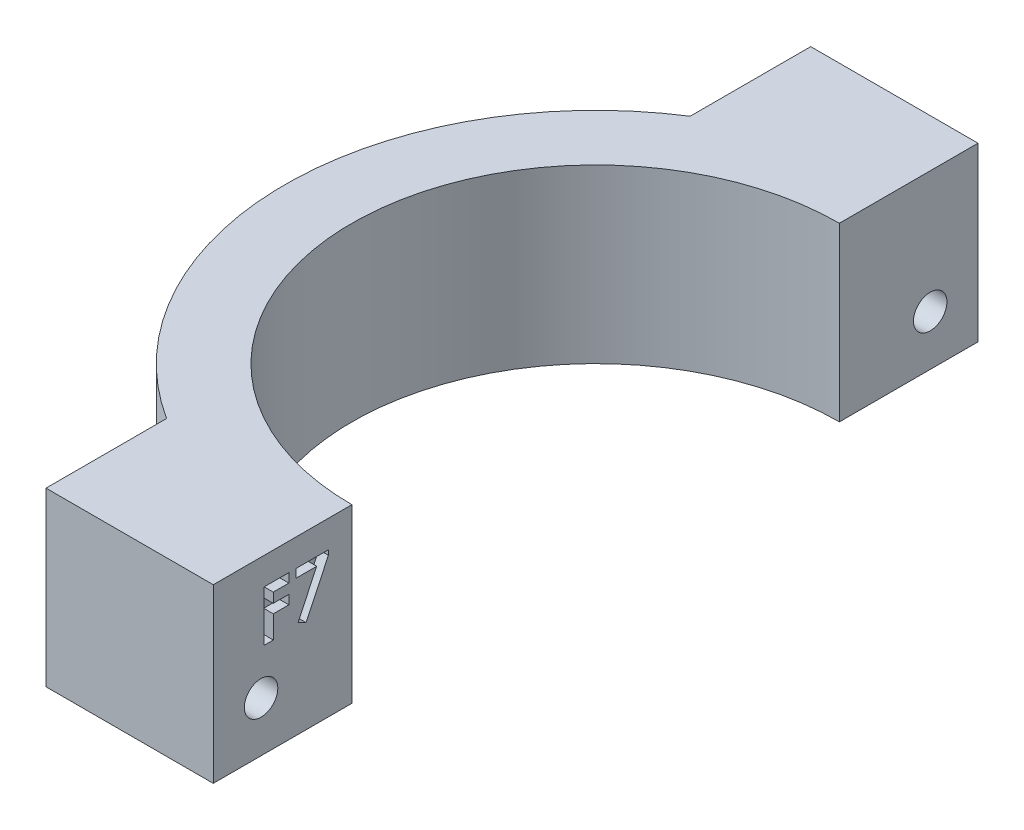
from build123d import *

# Parameters (mm, degrees)
BOSS_EXTRUDE1_DEPTH = 18
SKETCH2_R           = 1.75
CUT_EXTRUDE1_DEPTH  = 33.5
CUT_EXTRUDE2_DEPTH  = 1
CUT_EXTRUDE3_DEPTH  = 5


with BuildPart() as part:
    # Sketch1 → Boss-Extrude1 (new body)
    with BuildSketch(Plane(origin=(0, 0, 0), x_dir=(1, 0, 0), z_dir=(0, 1, 0))):
        with BuildLine():
            Line((-11.998275301, 32.528571429), (-29.498275301, 32.528571429))
            Line((-29.498275301, 32.528571429), (-29.498275301, 19.914699304))
            ThreePointArc((-29.498275301, 19.914699304), (-21.114218589, 23.723916882), (-11.998275301, 25.028571429))
            Line((-11.998275301, 25.028571429), (-11.998275301, 32.528571429))
        make_face()
        with BuildLine():
            ThreePointArc((-11.998275301, 25.028571429), (-21.114218589, 23.723916882), (-29.498275301, 19.914699304))
            ThreePointArc((-29.498275301, 19.914699304), (-44.498275301, -7.471428571), (-29.498275301, -34.857556447))
            ThreePointArc((-29.498275301, -34.857556447), (-21.114218589, -38.666774025), (-11.998275301, -39.971428571))
            Line((-11.998275301, -39.971428571), (-11.998275301, -32.971428571))
            ThreePointArc((-11.998275301, -32.971428571), (-37.498275301, -7.471428571), (-11.998275301, 18.028571429))
            Line((-11.998275301, 18.028571429), (-11.998275301, 25.028571429))
        make_face()
        with BuildLine():
            Line((-29.498275301, -34.857556447), (-29.498275301, -47.471428571))
            Line((-29.498275301, -47.471428571), (-11.998275301, -47.471428571))
            Line((-11.998275301, -47.471428571), (-11.998275301, -39.971428571))
            ThreePointArc((-11.998275301, -39.971428571), (-21.114218589, -38.666774025), (-29.498275301, -34.857556447))
        make_face()
    extrude(amount=BOSS_EXTRUDE1_DEPTH)

    # Sketch2 → Cut-Extrude1 (cut, through all)
    with BuildSketch(Plane(origin=(-11.998275301, 0, 0), x_dir=(0, 0, -1), z_dir=(1, 0, 0))):
        with Locations((-42.471428571, 5.25)):
            Circle(SKETCH2_R)
        with Locations((27.528571429, 5.25)):
            Circle(SKETCH2_R)
    extrude(amount=-CUT_EXTRUDE1_DEPTH, mode=Mode.SUBTRACT)

    # Sketch3 → Cut-Extrude2 (cut)
    with BuildSketch(Plane(origin=(-11.998275301, 0, 0), x_dir=(0, 0, -1), z_dir=(1, 0, 0))):
        Polygon((-42.144930844, 15.142571671), (-39.566939391, 15.142571671), (-39.566939391, 14.192785347), (-41.195144519, 14.192785347), (-41.195144519, 13.175157142), (-39.566939391, 13.175157142), (-39.566939391, 12.225370817), (-41.195144519, 12.225370817), (-41.195144519, 9.850905005), (-42.144930844, 9.850905005), align=None)
        Polygon((-38.820678707, 15.142571671), (-35.42858469, 15.142571671), (-35.42858469, 14.64965801), (-37.762769385, 9.715221244), (-38.603372684, 10.139232996), (-36.653978654, 14.260627227), (-38.820678707, 14.260627227), align=None)
    extrude(amount=-CUT_EXTRUDE2_DEPTH, mode=Mode.SUBTRACT)

    # Sketch4 → Cut-Extrude3 (cut)
    with BuildSketch(Plane.ZY.offset(29.498275301)):
        Polygon((45.042020782, 3.385760472), (45.371203467, 6.544078393), (42.800611256, 8.408317922), (39.900836361, 7.114239528), (39.571653676, 3.955921607), (42.142245887, 2.091682078), align=None)
        Polygon((-25.283205831, 3.004634402), (-24.461344982, 6.071860849), (-26.706710579, 8.317226447), (-29.773937026, 7.495365598), (-30.595797876, 4.428139151), (-28.350432278, 2.182773553), align=None)
    extrude(amount=-CUT_EXTRUDE3_DEPTH, mode=Mode.SUBTRACT)


solid = part.part
